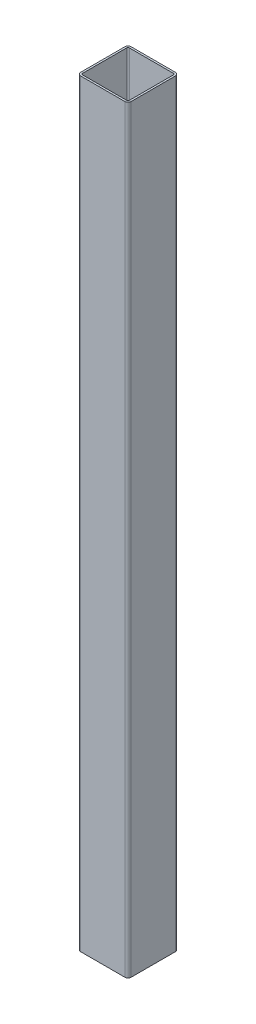
from build123d import *

# Parameters (mm, degrees)
EXTRUDE_1_DEPTH = 1200


with BuildPart() as part:
    # Эскиз1 → Вытянуть-Тонкостенный1 (new body)
    with BuildSketch(Plane(origin=(0, 0, 0), x_dir=(1, 0, 0), z_dir=(0, 1, 0))):
        with BuildLine():
            Line((-40, -35), (-40, 35))
            ThreePointArc((-40, 35), (-38.535533906, 38.535533906), (-35, 40))
            Line((-35, 40), (35, 40))
            ThreePointArc((35, 40), (38.535533906, 38.535533906), (40, 35))
            Line((40, 35), (40, -35))
            ThreePointArc((40, -35), (38.535533906, -38.535533906), (35, -40))
            Line((35, -40), (-35, -40))
            ThreePointArc((-35, -40), (-38.535533906, -38.535533906), (-40, -35))
        make_face()
        with BuildLine():
            Line((-37, -35), (-37, 35))
            ThreePointArc((-37, 35), (-36.414213562, 36.414213562), (-35, 37))
            Line((-35, 37), (35, 37))
            ThreePointArc((35, 37), (36.414213562, 36.414213562), (37, 35))
            Line((37, 35), (37, -35))
            ThreePointArc((37, -35), (36.414213562, -36.414213562), (35, -37))
            Line((35, -37), (-35, -37))
            ThreePointArc((-35, -37), (-36.414213562, -36.414213562), (-37, -35))
        make_face(mode=Mode.SUBTRACT)
    extrude(amount=EXTRUDE_1_DEPTH)


solid = part.part
